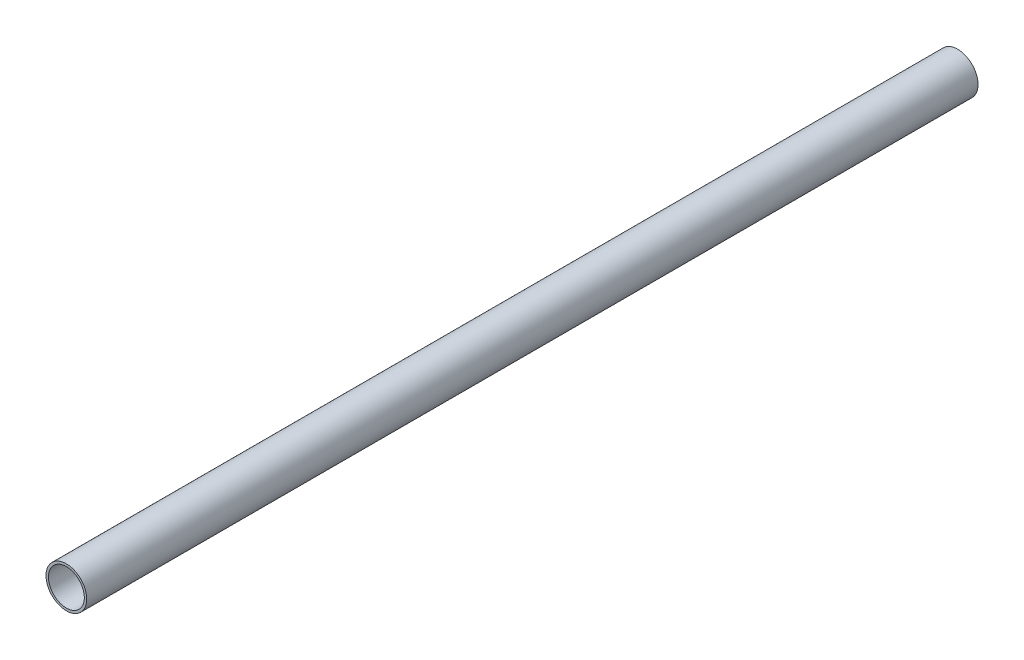
from build123d import *

# Parameters (mm, degrees)
SKETCH1_R      = 17
EXTRUDE1_DEPTH = 372
SHELL1_T       = -2


with BuildPart() as part:
    # Sketch1 → Extrude1 (new, symmetric)
    with BuildSketch(Plane.XY):
        with Locations(Location((0, 0, 0), (0, 0, 180))):
            Circle(SKETCH1_R)
    extrude(amount=EXTRUDE1_DEPTH, both=True)

    # Shell1
    shell1_openings = [part.faces().sort_by_distance(p)[0] for p in [
        (0, 0, 372),
    ]]
    offset(amount=SHELL1_T, openings=shell1_openings, kind=Kind.INTERSECTION)


solid = part.part
